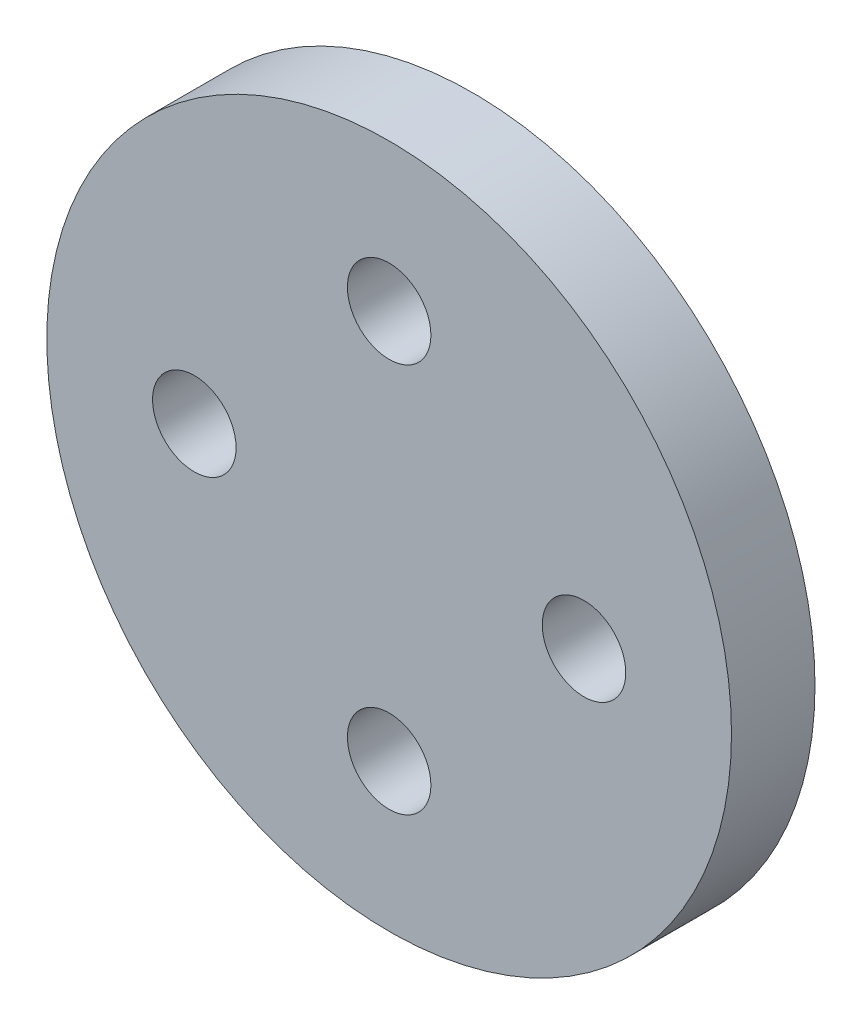
from build123d import *

# Parameters (mm, degrees)
SKETCH2_R           = 12.3
SKETCH2_R_2         = 1.5
BOSS_EXTRUDE1_DEPTH = 3
SKETCH3_R           = 3
BOSS_EXTRUDE2_DEPTH = 3


with BuildPart() as part:
    # Sketch2 → Boss-Extrude1 (new body)
    with BuildSketch(Plane.XY):
        Circle(SKETCH2_R)
        with Locations((-7, 0)):
            Circle(SKETCH2_R_2, mode=Mode.SUBTRACT)
        with Locations((0, 7)):
            Circle(SKETCH2_R_2, mode=Mode.SUBTRACT)
        with Locations((7, 0)):
            Circle(SKETCH2_R_2, mode=Mode.SUBTRACT)
        with Locations((0, -7)):
            Circle(SKETCH2_R_2, mode=Mode.SUBTRACT)
    extrude(amount=BOSS_EXTRUDE1_DEPTH)

    # Sketch3 → Boss-Extrude2 (add)
    with BuildSketch(Plane(origin=(0, 0, 0), x_dir=(-1, 0, 0), z_dir=(0, 0, -1))):
        Circle(SKETCH3_R)
    extrude(amount=BOSS_EXTRUDE2_DEPTH)


solid = part.part
